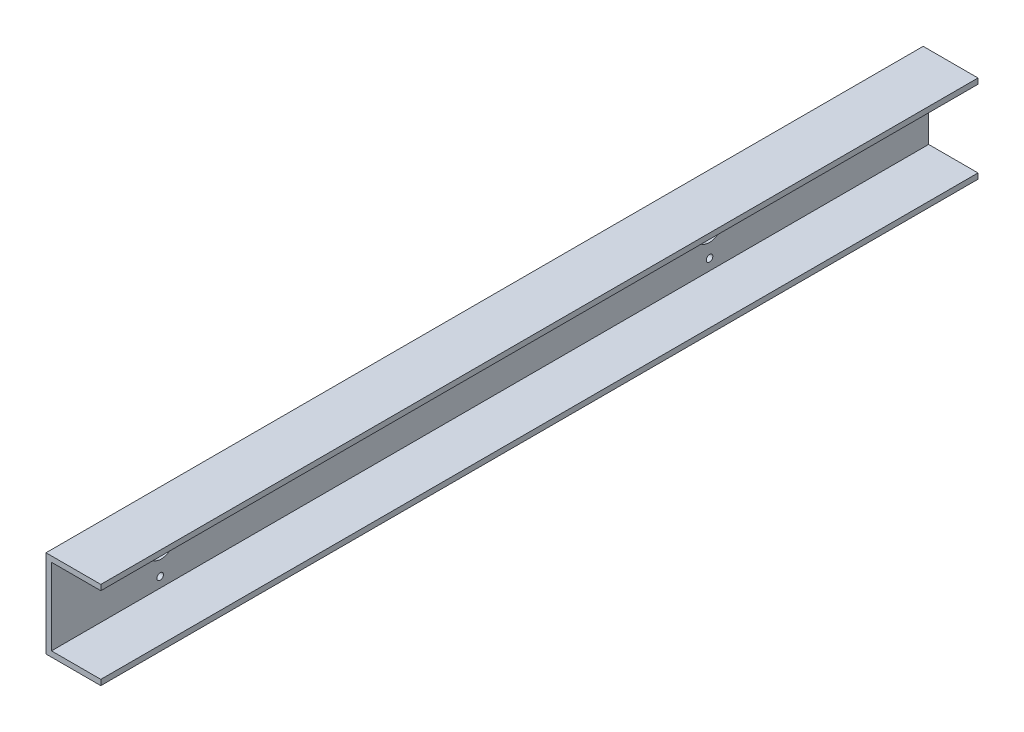
from build123d import *

# Parameters (mm, degrees)
BOSS_EXTRUDE1_DEPTH     = 400
SKETCH2_R               = 12.5
CUT_EXTRUDE1_DEPTH      = 1
CUT_EXTRUDE1_DEPTH_BACK = 51
SKETCH4_R               = 3
CUT_EXTRUDE2_DEPTH      = 1
CUT_EXTRUDE2_DEPTH_BACK = 51
SKETCH6_R               = 3
CUT_EXTRUDE3_DEPTH      = 1
CUT_EXTRUDE3_DEPTH_BACK = 51


with BuildPart() as part:
    # Sketch1 → Boss-Extrude1 (new body, symmetric)
    with BuildSketch(Plane.XY):
        Polygon((23.833333333, 42.5), (-26.166666667, 42.5), (-26.166666667, -37.5), (23.833333333, -37.5), (23.833333333, -32.5), (-21.166666667, -32.5), (-21.166666667, 37.5), (23.833333333, 37.5), align=None)
    extrude(amount=BOSS_EXTRUDE1_DEPTH, both=True)

    # Sketch2 → Cut-Extrude1 (cut, two sides)
    with BuildSketch(Plane.ZY.offset(26.166666667)) as cut_extrude1_sk:
        with Locations((-200, 2.5)):
            Circle(SKETCH2_R)
        with Locations((300, 2.5)):
            Circle(SKETCH2_R)
    extrude(amount=CUT_EXTRUDE1_DEPTH, mode=Mode.SUBTRACT)
    extrude(cut_extrude1_sk.sketch, amount=-CUT_EXTRUDE1_DEPTH_BACK, mode=Mode.SUBTRACT)

    # Sketch4 → Cut-Extrude2 (cut, two sides)
    with BuildSketch(Plane.ZY.offset(26.166666667)) as cut_extrude2_sk:
        with Locations((-200.1583434, 27.5)):
            Circle(SKETCH4_R)
        with Locations((-200.1583434, -22.5)):
            Circle(SKETCH4_R)
        with Locations((-175, 3.378177917)):
            Circle(SKETCH4_R)
        with Locations((-224.997353573, 2.863750384)):
            Circle(SKETCH4_R)
    extrude(amount=CUT_EXTRUDE2_DEPTH, mode=Mode.SUBTRACT)
    extrude(cut_extrude2_sk.sketch, amount=-CUT_EXTRUDE2_DEPTH_BACK, mode=Mode.SUBTRACT)

    # Sketch6 → Cut-Extrude3 (cut, two sides)
    with BuildSketch(Plane.ZY.offset(26.166666667)) as cut_extrude3_sk:
        with Locations((299.206047638, 26.660043497)):
            Circle(SKETCH6_R)
        with Locations((325.01367144, 2.494643569)):
            Circle(SKETCH6_R)
        with Locations((300.848271512, -23.312980234)):
            Circle(SKETCH6_R)
        with Locations((275.04064771, 0.852419694)):
            Circle(SKETCH6_R)
    extrude(amount=CUT_EXTRUDE3_DEPTH, mode=Mode.SUBTRACT)
    extrude(cut_extrude3_sk.sketch, amount=-CUT_EXTRUDE3_DEPTH_BACK, mode=Mode.SUBTRACT)


solid = part.part
